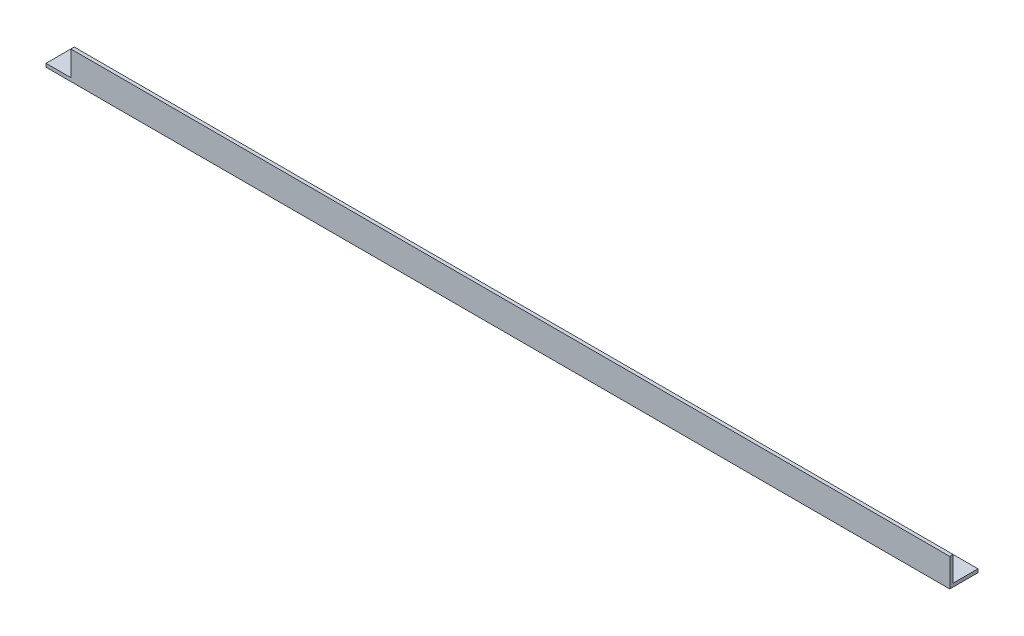
from build123d import *

# Parameters (mm, degrees)
EXTRUDE_1_DEPTH     = 800
SKETCH_2_W          = 22
SKETCH_2_H          = 22
CUT_EXTRUDE_1_DEPTH = 26


with BuildPart() as part:
    # Эскиз1 → Вытянуть-Тонкостенный1 (new body)
    with BuildSketch(Plane(origin=(0, 0, 0), x_dir=(0, 0, -1), z_dir=(1, 0, 0))):
        Polygon((0, 25), (0, 0), (25, 0), (25, 3), (3, 3), (3, 25), align=None)
    extrude(amount=EXTRUDE_1_DEPTH)

    # Эскиз2 → Вырез-Вытянуть1 (cut, through all)
    with BuildSketch(Plane.XY):
        with Locations((11, 14)):
            Rectangle(SKETCH_2_W, SKETCH_2_H)
    extrude(amount=-CUT_EXTRUDE_1_DEPTH, mode=Mode.SUBTRACT)


solid = part.part
